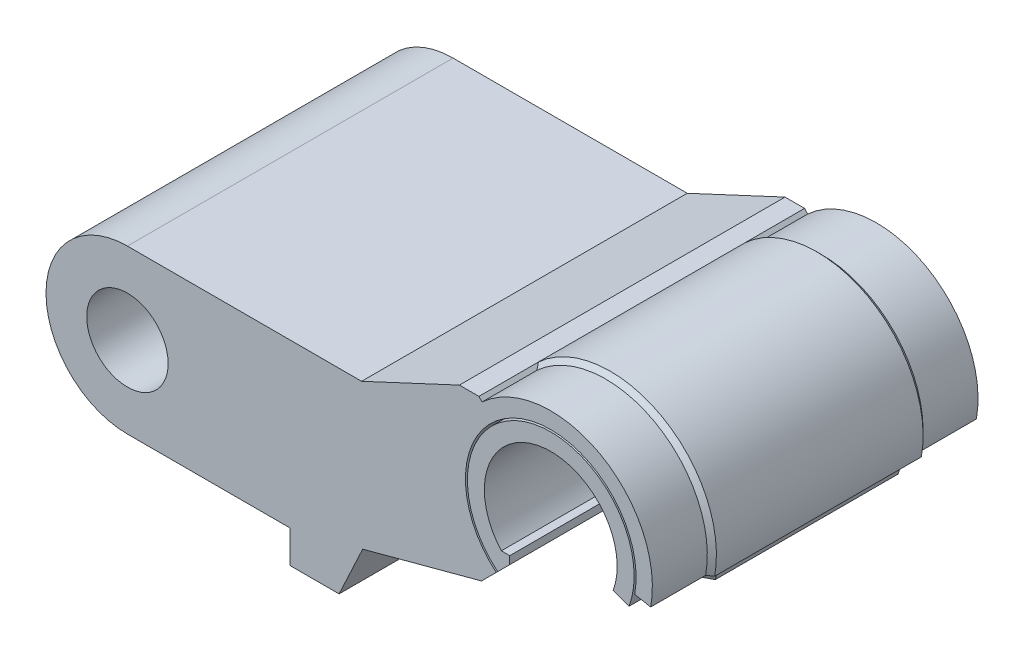
from build123d import *

# Parameters (mm, degrees)
BOSS_EXTRUDE1_DEPTH     = 25
CUT_EXTRUDE1_DEPTH      = 2.6
CUT_EXTRUDE2_DEPTH      = 26
CUT_EXTRUDE2_DEPTH_BACK = 26
BOSS_EXTRUDE2_DEPTH     = 25
BOSS_EXTRUDE3_START     = -9.134315
BOSS_EXTRUDE3_DEPTH     = 9.134315
SKETCH15_R              = 6.25
CUT_EXTRUDE3_DEPTH      = 26
CUT_EXTRUDE3_DEPTH_BACK = 26
CUT_EXTRUDE4_DEPTH      = 26
CUT_EXTRUDE4_DEPTH_BACK = 26


with BuildPart() as part:
    # Sketch3 → Boss-Extrude1 (new body, symmetric)
    with BuildSketch(Plane.XY):
        with BuildLine():
            Line((6.3, -8.014378278), (9.856597623, -11.570975901))
            ThreePointArc((9.856597623, -11.570975901), (0, 15.2), (-9.856597623, -11.570975901))
            Line((-9.856597623, -11.570975901), (-6.3, -8.014378278))
            Line((-6.3, -8.014378278), (-6.3, -6.814378278))
            Line((-6.3, -6.814378278), (-7.589746286, -6.814378278))
            ThreePointArc((-7.589746286, -6.814378278), (0, 10.2), (7.589746286, -6.814378278))
            Line((7.589746286, -6.814378278), (6.3, -6.814378278))
            Line((6.3, -6.814378278), (6.3, -8.014378278))
        make_face()
    extrude(amount=BOSS_EXTRUDE1_DEPTH, both=True)

    # Sketch4 → Cut-Extrude1 (cut, symmetric)
    with BuildSketch(Plane(origin=(0, 0, 0), x_dir=(0, 0, -1), z_dir=(1, 0, 0))):
        Polygon((-3.082842712, 15.2), (-9.482842712, 8.8), (9.482842712, 8.8), (3.082842712, 15.2), align=None)
    extrude(amount=CUT_EXTRUDE1_DEPTH, both=True, mode=Mode.SUBTRACT)

    # Sketch5 → Cut-Revolve1 (revolve, cut)
    with BuildSketch(Plane(origin=(0, 0, 0), x_dir=(0, 0, -1), z_dir=(1, 0, 0))):
        Polygon((25, 15.2), (25, 12.8), (16.441421356, 12.8), (14.041421356, 15.2), align=None)
    cut_revolve1 = revolve(axis=Axis((0, 0, 27.223610458), (0, 0, -1)), mode=Mode.SUBTRACT)

    # Mirror1: Cut-Revolve1 across plane
    add(cut_revolve1.mirror(Plane.XY), mode=Mode.SUBTRACT)

    # Sketch16 → Cut-Extrude4 (cut, two sides)
    with BuildSketch(Plane.XY) as cut_extrude4_sk:
        with BuildLine():
            Line((0, 0), (14.283327836, -5.198706179))
            ThreePointArc((14.283327836, -5.198706179), (8.718361833, -12.451111073), (0, -15.2))
            Line((0, -15.2), (0, 0))
        make_face()
    extrude(amount=CUT_EXTRUDE4_DEPTH, mode=Mode.SUBTRACT)
    extrude(cut_extrude4_sk.sketch, amount=-CUT_EXTRUDE4_DEPTH_BACK, mode=Mode.SUBTRACT)


with BuildPart() as body_2:
    # Sketch7 → Revolve1 (revolve)
    with BuildSketch(Plane(origin=(0, 0, 0), x_dir=(0, 0, -1), z_dir=(1, 0, 0))):
        Polygon((25, 13.1), (16.565685425, 13.1), (14.165685425, 15.5), (3.082842712, 15.5), (-3.082842712, 15.5), (-14.165685425, 15.5), (-16.565685425, 13.1), (-25, 13.1), (-25, 15.6), (-16.565685425, 15.6), (-15.865685425, 16.3), (15.865685425, 16.3), (16.565685425, 15.6), (25, 15.6), align=None)
    revolve(axis=Axis((0, 0, 29.952528939), (0, 0, -1)))

    # Sketch10 → Cut-Extrude2 (cut, two sides)
    with BuildSketch(Plane.XY) as cut_extrude2_sk:
        with BuildLine():
            Line((-6.3, -8.014378278), (-9.856597623, -11.570975901))
            Line((-9.856597623, -11.570975901), (-28.285621722, -30))
            Line((-28.285621722, -30), (0, -30))
            ThreePointArc((0, -30), (19.198137256, -23.052798657), (29.504719516, -5.428768394))
            Line((29.504719516, -5.428768394), (0, 0))
            Line((0, 0), (-6.3, -8.014378278))
        make_face()
    extrude(amount=CUT_EXTRUDE2_DEPTH, mode=Mode.SUBTRACT)
    extrude(cut_extrude2_sk.sketch, amount=-CUT_EXTRUDE2_DEPTH_BACK, mode=Mode.SUBTRACT)

    # Sketch12 → Boss-Extrude2 (add, symmetric)
    with BuildSketch(Plane.XY):
        with BuildLine():
            Line((-40, -20), (-40, -25))
            Line((-40, -25), (-32.5, -25))
            Line((-32.5, -25), (-28.881329228, -17.239735487))
            Line((-28.881329228, -17.239735487), (-10.636732158, -12.351110436))
            ThreePointArc((-10.636732158, -12.351110436), (-16.297860463, -0.264091534), (-11.031319051, 12))
            Line((-11.031319051, 12), (-14.031319051, 12))
            Line((-14.031319051, 12), (-29.042867494, 5))
            Line((-29.042867494, 5), (-65, 5))
            ThreePointArc((-65, 5), (-77.5, -7.5), (-65, -20))
            Line((-65, -20), (-40, -20))
        make_face()
    extrude(amount=BOSS_EXTRUDE2_DEPTH, both=True)

    # Sketch13 → Boss-Extrude3 (add)
    with BuildSketch(Plane(origin=(0, 0, -25), x_dir=(-1, 0, 0), z_dir=(0, 0, -1)).offset(BOSS_EXTRUDE3_START)):
        with BuildLine():
            Line((11.031319051, 12), (10.557581423, 11.484662577))
            ThreePointArc((10.557581423, 11.484662577), (15.597507546, -0.278851856), (10.140320888, -11.854699165))
            Line((10.140320888, -11.854699165), (10.636732158, -12.351110436))
            ThreePointArc((10.636732158, -12.351110436), (16.297860463, -0.264091534), (11.031319051, 12))
        make_face()
    boss_extrude3 = extrude(amount=BOSS_EXTRUDE3_DEPTH)

    # Mirror2: Boss-Extrude3 across plane
    add(boss_extrude3.mirror(Plane.XY))

    # Sketch15 → Cut-Extrude3 (cut, two sides)
    with BuildSketch(Plane.XY) as cut_extrude3_sk:
        with Locations((-65, -7.5)):
            Circle(SKETCH15_R)
    extrude(amount=CUT_EXTRUDE3_DEPTH, mode=Mode.SUBTRACT)
    extrude(cut_extrude3_sk.sketch, amount=-CUT_EXTRUDE3_DEPTH_BACK, mode=Mode.SUBTRACT)


solid = Compound([part.part, body_2.part])
